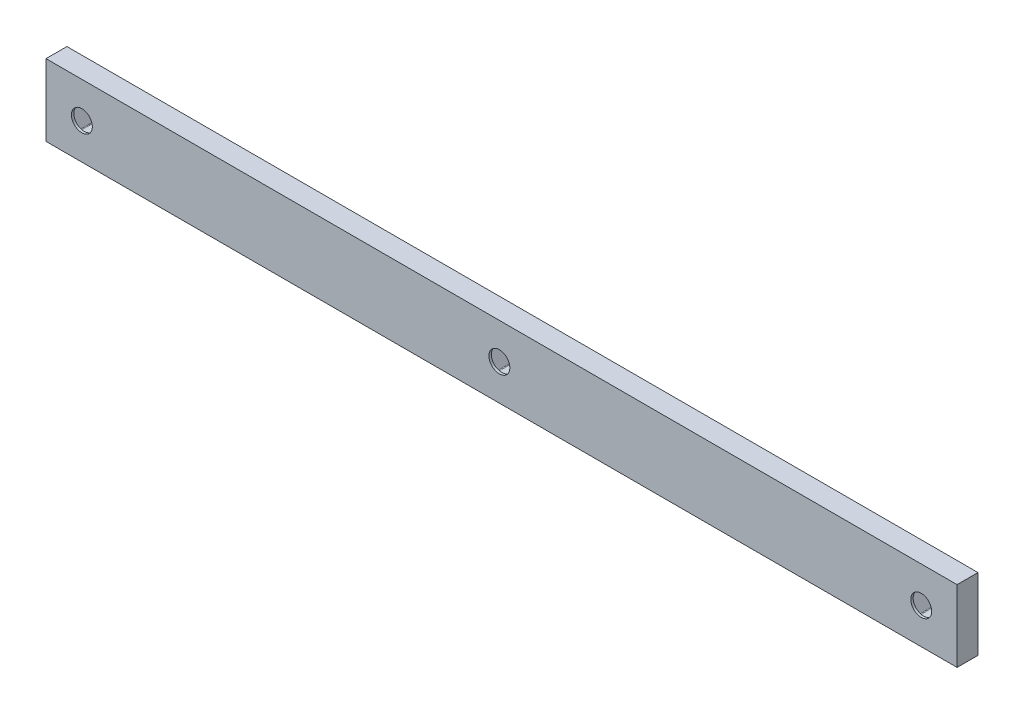
from build123d import *

# Parameters (mm, degrees)
SKETCH1_W                      = 152.421392062
SKETCH1_H                      = 12
BOSS_EXTRUDE1_DEPTH            = 3.5
CUT_EXTRUDE1_DEPTH             = 3.1
CUT_EXTRUDE2_DEPTH             = 3.1
CUT_EXTRUDE3_DEPTH             = 3.1
F_3_5_3_5_DIAMETER_HOLE1_D     = 3.5
F_3_5_3_5_DIAMETER_HOLE1_DEPTH = 0.4
FILLET1_R                      = 0.150000007


with BuildPart() as part:
    # Sketch1 → Boss-Extrude1 (new body)
    with BuildSketch(Plane(origin=(0, 0, 0), x_dir=(-1, 0, 0), z_dir=(0, 0, -1))):
        with Locations((15.639629555, 0)):
            Rectangle(SKETCH1_W, SKETCH1_H)
    extrude(amount=-BOSS_EXTRUDE1_DEPTH)

    # Sketch2 → Cut-Extrude1 (cut)
    with BuildSketch(Plane(origin=(0, 0, 0), x_dir=(-1, 0, 0), z_dir=(0, 0, -1))):
        Polygon((17.674321891, -2.900007341), (19.348637675, -7.335e-06), (17.674319972, 2.899992671), (14.325688404, 2.899992671), (12.651373579, -7.889e-06), (14.325690323, -2.900007341), align=None)
    extrude(amount=-CUT_EXTRUDE1_DEPTH, mode=Mode.SUBTRACT)

    # Sketch3 → Cut-Extrude2 (cut)
    with BuildSketch(Plane(origin=(0, 0, 0), x_dir=(-1, 0, 0), z_dir=(0, 0, -1))):
        Polygon((-57.919692896, -7.889e-06), (-56.245376153, -2.900007341), (-52.896744585, -2.900007341), (-51.2224288, -7.335e-06), (-52.896746503, 2.899992671), (-56.245378072, 2.899992671), align=None)
    extrude(amount=-CUT_EXTRUDE2_DEPTH, mode=Mode.SUBTRACT)

    # Sketch4 → Cut-Extrude3 (cut)
    with BuildSketch(Plane(origin=(0, 0, 0), x_dir=(-1, 0, 0), z_dir=(0, 0, -1))):
        Polygon((82.501699166, -7.889e-06), (84.176015909, -2.900007341), (87.524647477, -2.900007341), (89.198963262, -7.335e-06), (87.524645559, 2.899992671), (84.17601399, 2.899992671), align=None)
    extrude(amount=-CUT_EXTRUDE3_DEPTH, mode=Mode.SUBTRACT)

    # Ø3.5 (3.5) Diameter Hole1
    with Locations(Plane(origin=(0, 0, 3.1), x_dir=(-1, 0, 0), z_dir=(0, 0, -1))):
        with Locations((-54.571061328, 6.781e-06), (85.850330734, 6.781e-06), (16, 0)):
            Hole(F_3_5_3_5_DIAMETER_HOLE1_D / 2, depth=F_3_5_3_5_DIAMETER_HOLE1_DEPTH)

    # Fillet1
    fillet1_edges = [part.edges().sort_by_distance(p)[0] for p in [
        (-17.674321891, -2.900007341, 1.55),
        (-14.325690323, -2.900007341, 1.55),
        (-12.651373579, -7.889e-06, 1.55),
        (-14.325688404, 2.899992671, 1.55),
        (-17.674319972, 2.899992671, 1.55),
        (-19.348637675, -7.335e-06, 1.55),
        (57.919692896, -7.889e-06, 1.55),
        (56.245378072, 2.899992671, 1.55),
        (52.896746503, 2.899992671, 1.55),
        (51.2224288, -7.335e-06, 1.55),
        (52.896744585, -2.900007341, 1.55),
        (56.245376153, -2.900007341, 1.55),
        (-82.501699166, -7.889e-06, 1.55),
        (-84.17601399, 2.899992671, 1.55),
        (-87.524645559, 2.899992671, 1.55),
        (-89.198963262, -7.335e-06, 1.55),
        (-87.524647477, -2.900007341, 1.55),
        (-84.176015909, -2.900007341, 1.55),
    ]]
    fillet(fillet1_edges, radius=FILLET1_R)


solid = part.part
